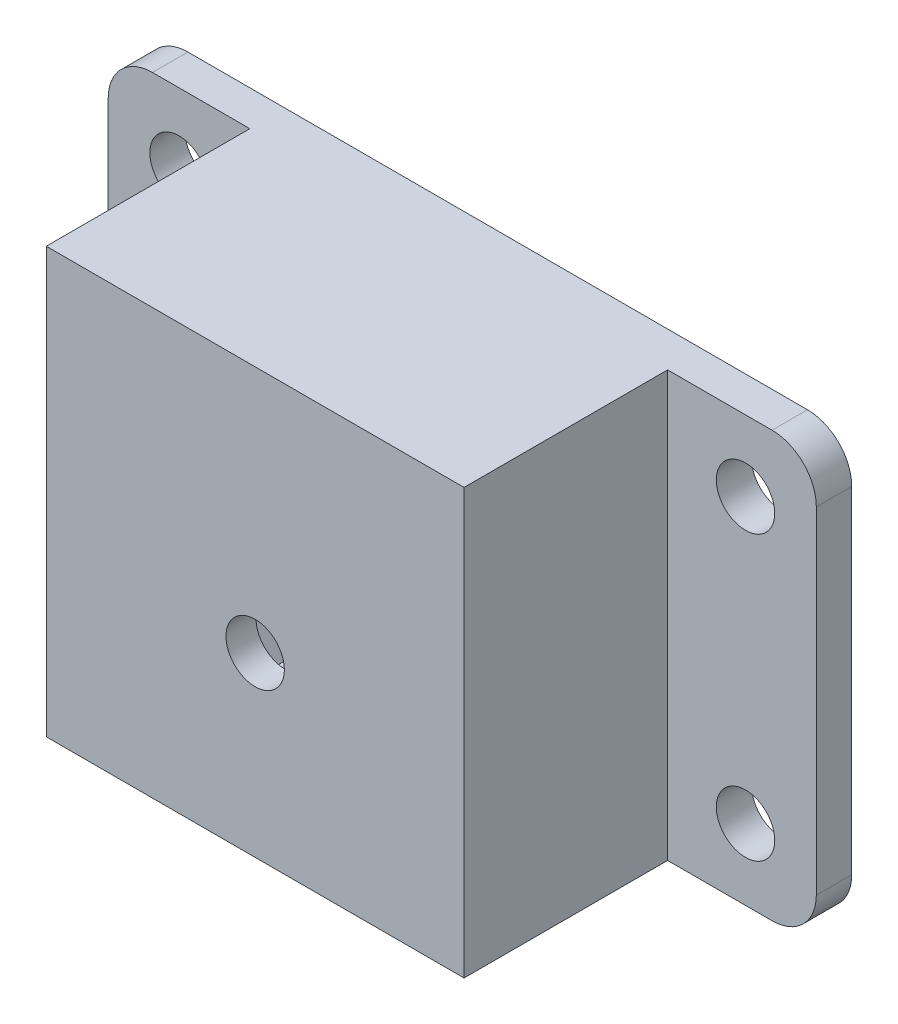
from build123d import *

# Parameters (mm, degrees)
SKETCH1_R           = 1.65
BOSS_EXTRUDE1_DEPTH = 2
BOSS_EXTRUDE2_DEPTH = 5.5
SKETCH3_W           = 23.6
SKETCH3_H           = 24
SKETCH3_R           = 1.65
BOSS_EXTRUDE3_DEPTH = 6
CUT_EXTRUDE1_START  = -1.7
CUT_EXTRUDE1_DEPTH  = 2.6
FILLET1_R           = 2.5


with BuildPart() as part:
    # Sketch1 → Boss-Extrude1 (new body)
    with BuildSketch(Plane(origin=(0, 0, 0), x_dir=(0, 1, 0), z_dir=(0, 0, 1))):
        Polygon((-24, 12.4), (-4, 12.4), (-4, 28), (-24, 28), (-24, 40), (0, 40), (0, 0), (-24, 0), align=None)
        with Locations((-20, 4)):
            Circle(SKETCH1_R, mode=Mode.SUBTRACT)
        with Locations((-4, 4)):
            Circle(SKETCH1_R, mode=Mode.SUBTRACT)
        with Locations((-4, 36)):
            Circle(SKETCH1_R, mode=Mode.SUBTRACT)
        with Locations((-20, 36)):
            Circle(SKETCH1_R, mode=Mode.SUBTRACT)
    extrude(amount=BOSS_EXTRUDE1_DEPTH)

    # Sketch2 → Boss-Extrude2 (add)
    with BuildSketch(Plane.XY.offset(2)):
        Polygon((-28, -24), (-28, -4), (-12.4, -4), (-12.4, -24), (-8.4, -24), (-8.4, 0), (-32, 0), (-32, -24), align=None)
    extrude(amount=BOSS_EXTRUDE2_DEPTH)

    # Sketch3 → Boss-Extrude3 (add)
    with BuildSketch(Plane.XY.offset(7.5)):
        with Locations((-20.2, -12)):
            Rectangle(SKETCH3_W, SKETCH3_H)
        with Locations((-20.2, -14)):
            Circle(SKETCH3_R, mode=Mode.SUBTRACT)
    extrude(amount=BOSS_EXTRUDE3_DEPTH)

    # Sketch4 → Cut-Extrude1 (cut)
    with BuildSketch(Plane.XY.offset(13.5).offset(CUT_EXTRUDE1_START)):
        Polygon((-16.851368439, -14), (-18.525684219, -11.1), (-21.874315781, -11.1), (-23.548631561, -14), (-21.874315781, -16.9), (-18.525684219, -16.9), align=None)
    extrude(amount=-CUT_EXTRUDE1_DEPTH, mode=Mode.SUBTRACT)

    # Fillet1
    fillet1_edges = [part.edges().sort_by_distance(p)[0] for p in [
        (0, 0, 1),
        (0, -24, 1),
        (-40, -24, 1),
        (-40, 0, 1),
    ]]
    fillet(fillet1_edges, radius=FILLET1_R)


solid = part.part
